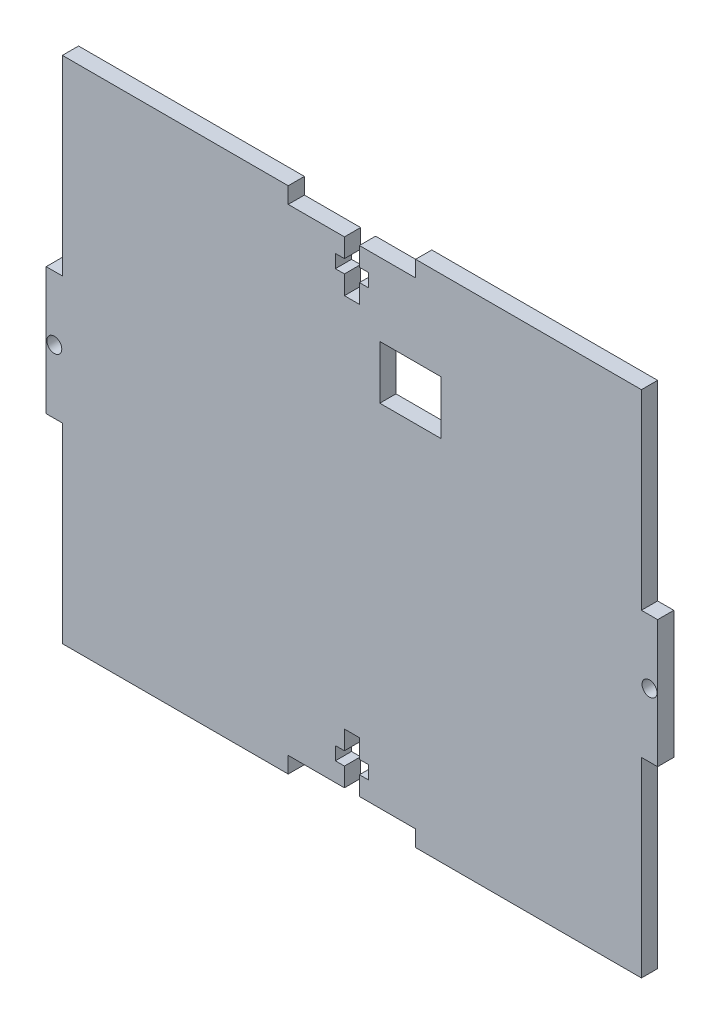
from build123d import *

# Parameters (mm, degrees)
SKETCH1_R           = 1.47
BOSS_EXTRUDE1_DEPTH = 1.5875
CUT_EXTRUDE1_DEPTH  = 4.175


with BuildPart() as part:
    # Sketch1 → Boss-Extrude1 (new body, symmetric)
    with BuildSketch(Plane.XY):
        Polygon((-12.5, 50), (-56.825, 50), (-56.825, 12.5), (-60, 12.5), (-60, -12.5), (-56.825, -12.5), (-56.825, -50), (-12.5, -50), (-12.5, -46.825), (-1.47, -46.825), (-1.47, -43.125), (-3.25, -43.125), (-3.25, -40.525), (-1.47, -40.525), (-1.47, -36.825), (1.47, -36.825), (1.47, -40.525), (3.25, -40.525), (3.25, -43.125), (1.47, -43.125), (1.47, -46.825), (12.5, -46.825), (12.5, -50), (56.825, -50), (56.825, -12.5), (60, -12.5), (60, 12.5), (56.825, 12.5), (56.825, 50), (12.5, 50), (12.5, 46.825), (1.47, 46.825), (1.47, 43.125), (3.25, 43.125), (3.25, 40.525), (1.47, 40.525), (1.47, 36.825), (-1.47, 36.825), (-1.47, 40.525), (-3.25, 40.525), (-3.25, 43.125), (-1.47, 43.125), (-1.47, 46.825), (-12.5, 46.825), align=None)
        with Locations((-58.4125, 0)):
            Circle(SKETCH1_R, mode=Mode.SUBTRACT)
        with Locations((58.4125, 0)):
            Circle(SKETCH1_R, mode=Mode.SUBTRACT)
    extrude(amount=BOSS_EXTRUDE1_DEPTH, both=True)

    # Sketch2 → Cut-Extrude1 (cut, through all)
    with BuildSketch(Plane(origin=(0, 0, -1.5875), x_dir=(-1, 0, 0), z_dir=(0, 0, -1))):
        Polygon((-5.975, 32.525), (-16.975, 32.525), (-17.475, 32.525), (-17.475, 32.025), (-17.475, 22.525), (-17.475, 22.025), (-16.975, 22.025), (-5.975, 22.025), (-5.475, 22.025), (-5.475, 22.525), (-5.475, 32.025), (-5.475, 32.525), align=None)
    extrude(amount=-CUT_EXTRUDE1_DEPTH, mode=Mode.SUBTRACT)


solid = part.part
